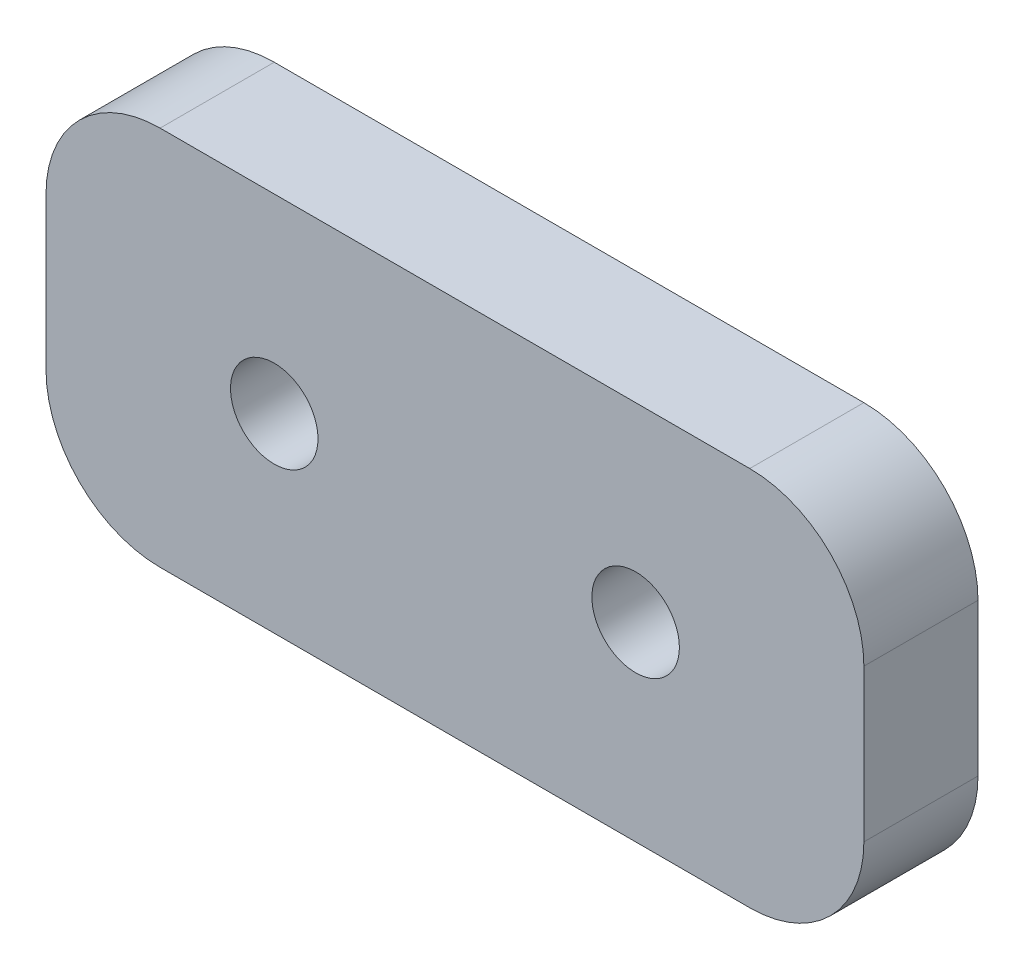
from build123d import *

# Parameters (mm, degrees)
SKETCH_1_W      = 21.5
SKETCH_1_H      = 10
SKETCH_1_R      = 1.15
EXTRUDE_1_DEPTH = 3
FILLET_1_R      = 3


with BuildPart() as part:
    # 草图1 → 凸台-拉伸1 (new body)
    with BuildSketch(Plane.XY):
        with Locations((10.75, 5)):
            Rectangle(SKETCH_1_W, SKETCH_1_H)
        with Locations((6, 5)):
            Circle(SKETCH_1_R, mode=Mode.SUBTRACT)
        with Locations((15.5, 5)):
            Circle(SKETCH_1_R, mode=Mode.SUBTRACT)
    extrude(amount=EXTRUDE_1_DEPTH)

    # 圆角1
    fillet_1_edges = [part.edges().sort_by_distance(p)[0] for p in [
        (0, 10, 1.5),
        (21.5, 10, 1.5),
        (21.5, 0, 1.5),
        (0, 0, 1.5),
    ]]
    fillet(fillet_1_edges, radius=FILLET_1_R)


solid = part.part
